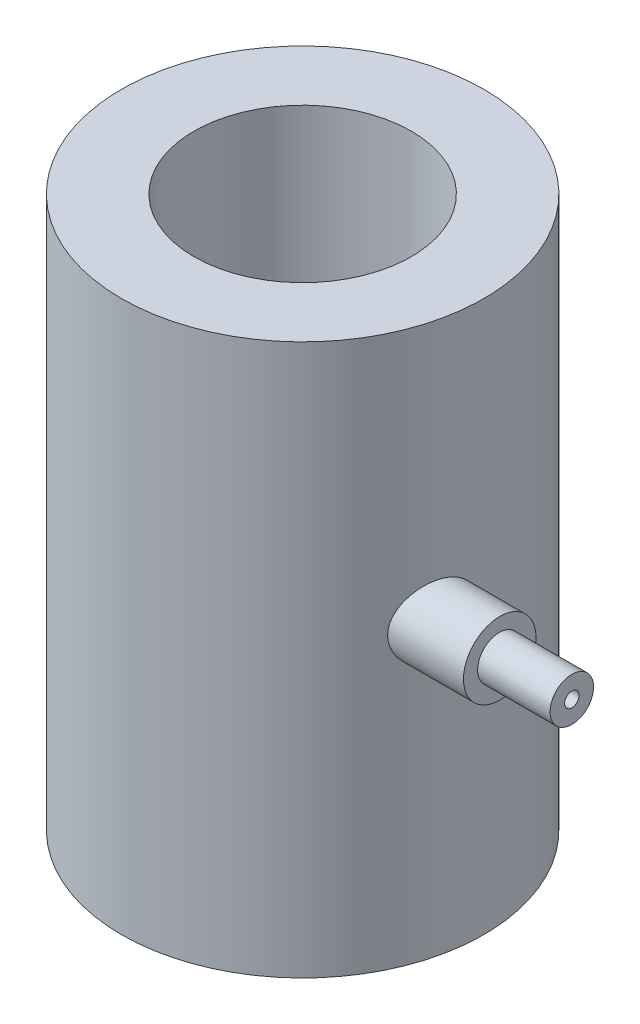
from build123d import *

# Parameters (mm, degrees)
CROQUIS1_R              = 12.5
CROQUIS1_R_2            = 7.5
SALIENTE_EXTRUIR1_DEPTH = 38
CROQUIS2_R              = 2.5
SALIENTE_EXTRUIR2_DEPTH = 16.5
CROQUIS3_R              = 7.5
CORTAR_EXTRUIR1_DEPTH   = 38
CROQUIS4_R              = 1.5
SALIENTE_EXTRUIR7_DEPTH = 5
CROQUIS5_R              = 0.5
CORTAR_EXTRUIR2_DEPTH   = 22
ESCALA1_SCALE           = 7


with BuildPart() as part:
    # Croquis1 → Saliente-Extruir1 (new body)
    with BuildSketch(Plane(origin=(0, 0, 0), x_dir=(1, 0, 0), z_dir=(0, 1, 0))):
        Circle(CROQUIS1_R)
        Circle(CROQUIS1_R_2, mode=Mode.SUBTRACT)
    extrude(amount=SALIENTE_EXTRUIR1_DEPTH)

    # Croquis2 → Saliente-Extruir2 (add)
    with BuildSketch(Plane(origin=(0, 0, 0), x_dir=(0, 0, -1), z_dir=(1, 0, 0))):
        with Locations((-2.905741876, 19.965132916)):
            Circle(CROQUIS2_R)
    extrude(amount=SALIENTE_EXTRUIR2_DEPTH)

    # Croquis3 → Cortar-Extruir1 (cut)
    with BuildSketch(Plane(origin=(0, 38, 0), x_dir=(1, 0, 0), z_dir=(0, 1, 0))):
        Circle(CROQUIS3_R)
    extrude(amount=-CORTAR_EXTRUIR1_DEPTH, mode=Mode.SUBTRACT)

    # Croquis4 → Saliente-Extruir7 (add)
    with BuildSketch(Plane(origin=(16.5, 0, 0), x_dir=(0, 0, -1), z_dir=(1, 0, 0))):
        with Locations((-2.933411735, 20.021455872)):
            Circle(CROQUIS4_R)
    extrude(amount=SALIENTE_EXTRUIR7_DEPTH)

    # Croquis5 → Cortar-Extruir2 (cut)
    with BuildSketch(Plane(origin=(21.5, 0, 0), x_dir=(0, 0, -1), z_dir=(1, 0, 0))):
        with Locations((-2.933411735, 20.021455872)):
            Circle(CROQUIS5_R)
    extrude(amount=-CORTAR_EXTRUIR2_DEPTH, mode=Mode.SUBTRACT)


with BuildPart() as part_1:
    # Escala1: scaled about (0.144888953, 19.008953835, 0.027312828)
    add(part.part.scale(ESCALA1_SCALE).moved(Location((-0.869333718, -114.05372301, -0.163876968))))


solid = part_1.part
